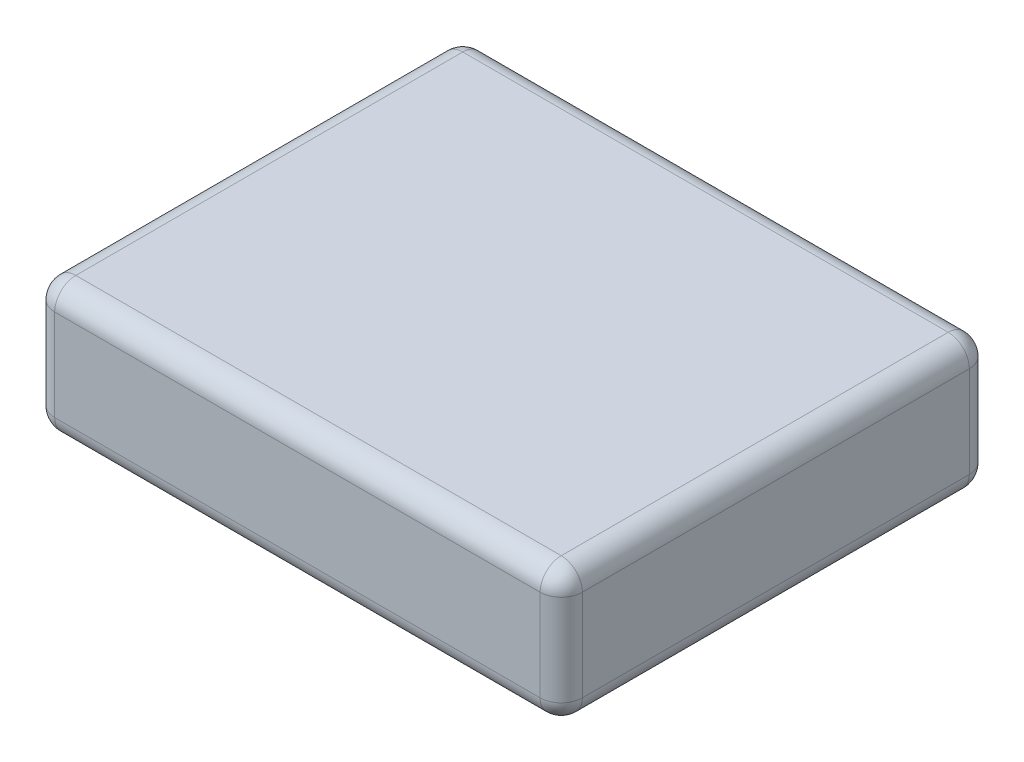
from build123d import *

# Parameters (mm, degrees)
SKETCH1_W           = 75
SKETCH1_H           = 61
BOSS_EXTRUDE1_DEPTH = 19
FILLET1_R           = 3


with BuildPart() as part:
    # Sketch1 → Boss-Extrude1 (new body)
    with BuildSketch(Plane(origin=(0, 0, 0), x_dir=(1, 0, 0), z_dir=(0, 1, 0))):
        Rectangle(SKETCH1_W, SKETCH1_H)
    extrude(amount=BOSS_EXTRUDE1_DEPTH)

    # Fillet1
    fillet1_edges = [part.edges().sort_by_distance(p)[0] for p in [
        (37.5, 19, 0),
        (0, 19, -30.5),
        (-37.5, 19, 0),
        (0, 0, -30.5),
        (37.5, 0, 0),
        (0, 0, 30.5),
        (-37.5, 0, 0),
        (-37.5, 9.5, -30.5),
        (37.5, 9.5, -30.5),
        (37.5, 9.5, 30.5),
        (-37.5, 9.5, 30.5),
        (0, 19, 30.5),
    ]]
    fillet(fillet1_edges, radius=FILLET1_R)


solid = part.part
